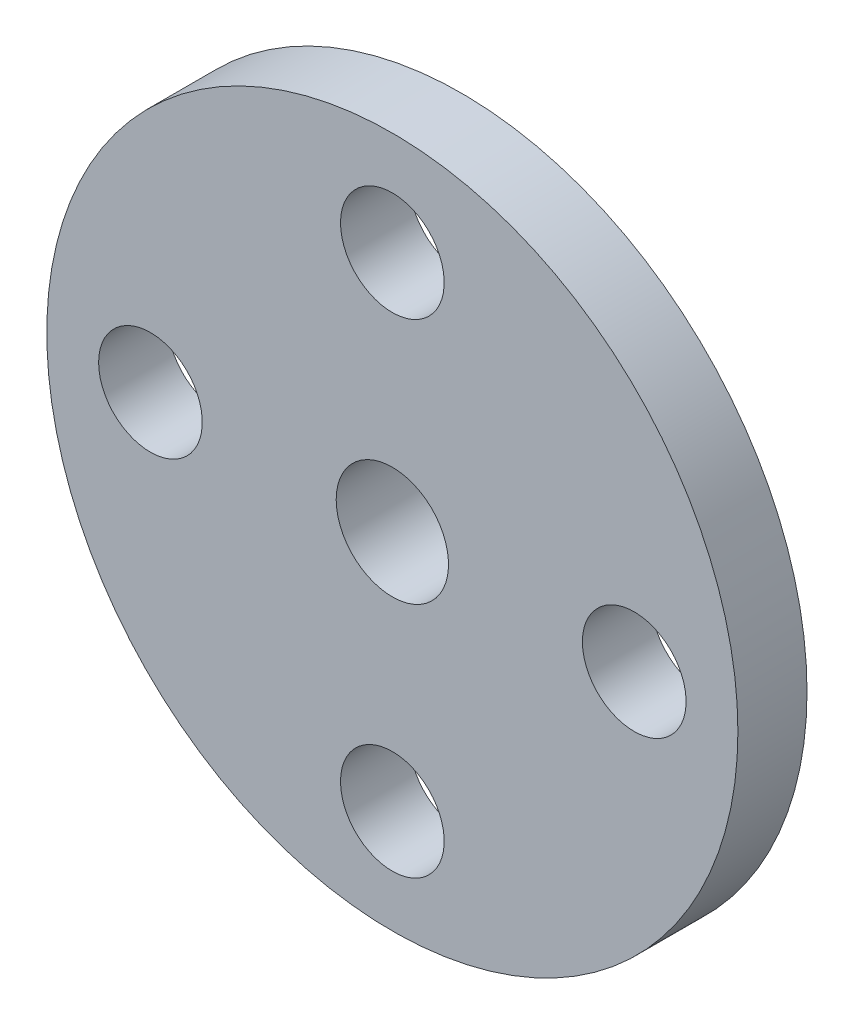
from build123d import *

# Parameters (mm, degrees)
SCHIZZO14_R                  = 10
ESTRUSIONE_ESTRUSIONE2_DEPTH = 2
FORO_3_0_3_1_D               = 3
SCHIZZO19_R                  = 4.5
ESTRUSIONE_ESTRUSIONE3_DEPTH = 2
SCHIZZO20_R                  = 1.625
TAGLIO_ESTRUSIONE1_DEPTH     = 5


with BuildPart() as part:
    # Schizzo14 → Estrusione-Estrusione2 (new body)
    with BuildSketch(Plane.XY):
        Circle(SCHIZZO14_R)
    extrude(amount=ESTRUSIONE_ESTRUSIONE2_DEPTH)

    # Foro Ø3.0 (3)-1 (through all)
    with Locations(Plane(origin=(7, 0, 0), x_dir=(-1, 0, 0), z_dir=(0, 0, -1))):
        with Locations((0, 0), (14, 0), (7, -7), (7, 7)):
            Hole(FORO_3_0_3_1_D / 2)

    # Schizzo19 → Estrusione-Estrusione3 (add)
    with BuildSketch(Plane.XY):
        Circle(SCHIZZO19_R)
    extrude(amount=-ESTRUSIONE_ESTRUSIONE3_DEPTH)

    # Schizzo20 → Taglio-Estrusione1 (cut, through all)
    with BuildSketch(Plane(origin=(0, 0, -2), x_dir=(-1, 0, 0), z_dir=(0, 0, -1))):
        Circle(SCHIZZO20_R)
    extrude(amount=-TAGLIO_ESTRUSIONE1_DEPTH, mode=Mode.SUBTRACT)


solid = part.part
